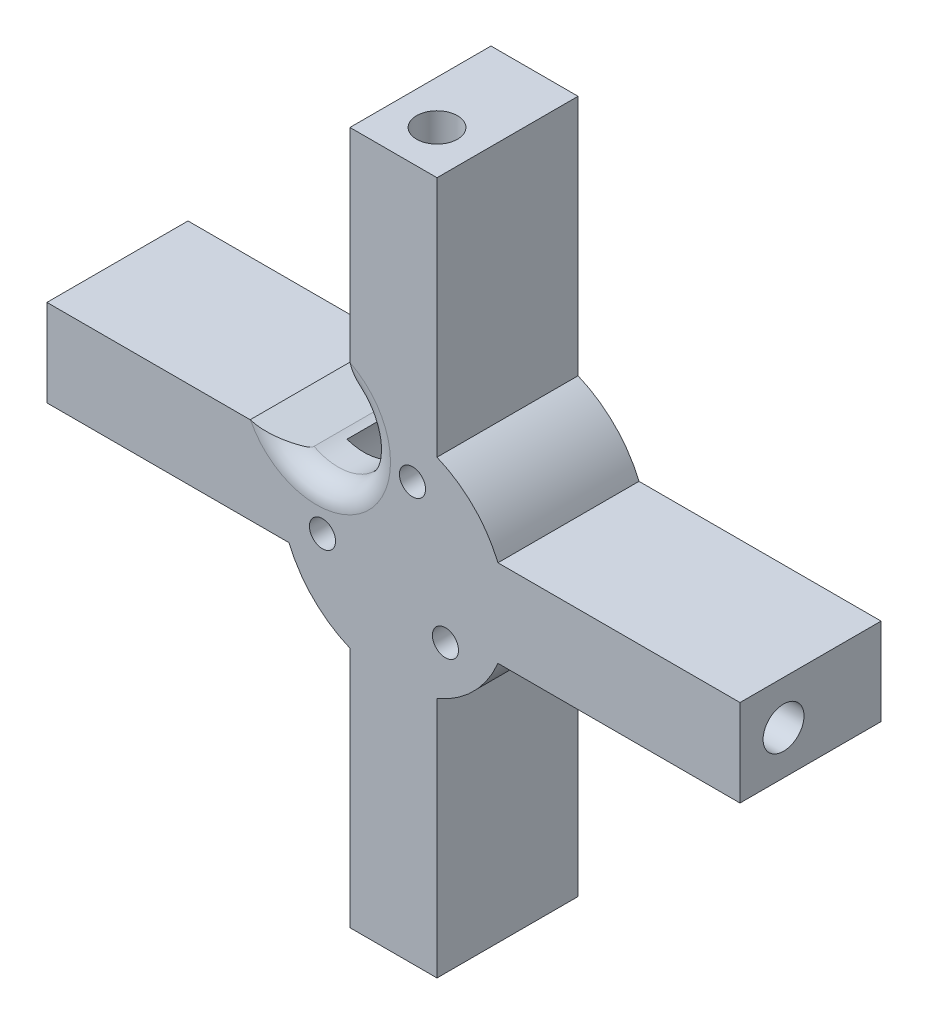
from build123d import *

# Parameters (mm, degrees)
BOSS_EXTRUDE1_DEPTH     = 22.7
SKETCH5_R               = 1.5
CUT_EXTRUDE1_DEPTH      = 70
CUT_EXTRUDE3_DEPTH      = 17.25
CUT_EXTRUDE3_DEPTH_BACK = 17.25
SKETCH6_R               = 11.25
SKETCH7_R               = 2
CUT_EXTRUDE4_DEPTH      = 3
CUT_EXTRUDE5_DEPTH      = 58
CUT_EXTRUDE5_DEPTH_BACK = 66
SKETCH8_W               = 6.5
SKETCH8_H               = 79.6
SKETCH9_R               = 2.35
SKETCH9_R_2             = 1.55
CUT_EXTRUDE7_DEPTH      = 4
SKETCH9_3_R             = 1.55
CUT_EXTRUDE20_DEPTH     = 12
SKETCH21_R              = 2.35
SKETCH21_R_2            = 1.55
CUT_EXTRUDE22_DEPTH     = 4
SKETCH21_2_R            = 1.55
CUT_EXTRUDE23_DEPTH     = 12
CUT_EXTRUDE24_START     = -4
SKETCH19_R              = 2.35
SKETCH19_R_2            = 1.55
CUT_EXTRUDE24_DEPTH     = 4
CUT_EXTRUDE25_START     = -12
SKETCH19_2_R            = 1.55
CUT_EXTRUDE25_DEPTH     = 12
CUT_EXTRUDE26_START     = -4
SKETCH20_R              = 2.35
SKETCH20_R_2            = 1.55
CUT_EXTRUDE26_DEPTH     = 4
CUT_EXTRUDE27_START     = -12
SKETCH20_2_R            = 1.55
CUT_EXTRUDE27_DEPTH     = 12
FILLET2_R               = 2.5
BOSS_EXTRUDE2_DEPTH     = 0.5


with BuildPart() as part:
    # Sketch4 → Boss-Extrude1 (new body)
    with BuildSketch(Plane.XY):
        with BuildLine():
            Line((-5, 39.8), (-5, 12))
            ThreePointArc((-5, 12), (-9.192388155, 9.192388155), (-12, 5))
            Line((-12, 5), (-39.8, 5))
            Line((-39.8, 5), (-39.8, -5))
            Line((-39.8, -5), (-12, -5))
            ThreePointArc((-12, -5), (-9.192388155, -9.192388155), (-5, -12))
            Line((-5, -12), (-5, -39.8))
            Line((-5, -39.8), (5, -39.8))
            Line((5, -39.8), (5, -12))
            ThreePointArc((5, -12), (9.192388155, -9.192388155), (12, -5))
            Line((12, -5), (39.8, -5))
            Line((39.8, -5), (39.8, 5))
            Line((39.8, 5), (12, 5))
            ThreePointArc((12, 5), (9.192388155, 9.192388155), (5, 12))
            Line((5, 12), (5, 39.8))
            Line((5, 39.8), (-5, 39.8))
        make_face()
    extrude(amount=-BOSS_EXTRUDE1_DEPTH)

    # Sketch5 → Cut-Extrude1 (cut)
    with BuildSketch(Plane.XY):
        with Locations((2.184887392, 8.154110756)):
            Circle(SKETCH5_R)
        with Locations((-8.154110756, -2.184887392)):
            Circle(SKETCH5_R)
        with Locations((5.969223364, -5.969223364)):
            Circle(SKETCH5_R)
        with BuildLine():
            Line((-5, 16.456455054), (-3.523070126, 11.621395871))
            ThreePointArc((-3.523070126, 11.621395871), (-4.596194078, 4.596194078), (-11.621395871, 3.523070126))
            Line((-11.621395871, 3.523070126), (-16.456455054, 5))
            Line((-16.456455054, 5), (-14.526937175, 6.929517879))
            ThreePointArc((-14.526937175, 6.929517879), (-13.081475452, 13.081475452), (-6.929517879, 14.526937175))
            Line((-6.929517879, 14.526937175), (-5, 16.456455054))
        make_face()
    extrude(amount=-CUT_EXTRUDE1_DEPTH, mode=Mode.SUBTRACT)

    # Sketch6 → Cut-Extrude3 (cut, two sides: drawn at the far end of the back side and taken through both)
    with BuildSketch(Plane(origin=(0, 0, -22.7), x_dir=(-1, 0, 0), z_dir=(0, 0, -1)).offset(-CUT_EXTRUDE3_DEPTH_BACK)):
        Circle(SKETCH6_R)
    extrude(amount=CUT_EXTRUDE3_DEPTH + CUT_EXTRUDE3_DEPTH_BACK, mode=Mode.SUBTRACT)

    # Sketch7 → Cut-Extrude4 (cut)
    with BuildSketch(Plane(origin=(0, 0, -5.45), x_dir=(-1, 0, 0), z_dir=(0, 0, -1))):
        with Locations((-2.184887392, 8.154110756)):
            Circle(SKETCH7_R)
        with Locations((-5.969223364, -5.969223364)):
            Circle(SKETCH7_R)
        with Locations((8.154110756, -2.184887392)):
            Circle(SKETCH7_R)
    extrude(amount=-CUT_EXTRUDE4_DEPTH, mode=Mode.SUBTRACT)

    # Sketch8 → Cut-Extrude5 (cut, two sides: drawn at the far end of the back side and taken through both)
    with BuildSketch(Plane.ZY.offset(5).offset(-CUT_EXTRUDE5_DEPTH_BACK)):
        with Locations((-19.45, 0)):
            Rectangle(SKETCH8_W, SKETCH8_H)
    extrude(amount=CUT_EXTRUDE5_DEPTH + CUT_EXTRUDE5_DEPTH_BACK, mode=Mode.SUBTRACT)

    # Sketch9 → Cut-Extrude7 (cut)
    with BuildSketch(Plane(origin=(0, 39.8, 0), x_dir=(1, 0, 0), z_dir=(0, 1, 0))):
        with Locations((0, 5)):
            Circle(SKETCH9_R)
        with Locations((0, 5)):
            Circle(SKETCH9_R_2, mode=Mode.SUBTRACT)
    extrude(amount=-CUT_EXTRUDE7_DEPTH, mode=Mode.SUBTRACT)

    # Sketch9_3 → Cut-Extrude20 (cut)
    with BuildSketch(Plane(origin=(0, 39.8, 0), x_dir=(1, 0, 0), z_dir=(0, 1, 0))):
        with Locations((0, 5)):
            Circle(SKETCH9_3_R)
    extrude(amount=-CUT_EXTRUDE20_DEPTH, mode=Mode.SUBTRACT)

    # Sketch21 → Cut-Extrude22 (cut)
    with BuildSketch(Plane.ZY.offset(39.8)):
        with Locations((-5, 0)):
            Circle(SKETCH21_R)
        with Locations((-5, 0)):
            Circle(SKETCH21_R_2, mode=Mode.SUBTRACT)
    extrude(amount=-CUT_EXTRUDE22_DEPTH, mode=Mode.SUBTRACT)

    # Sketch21_2 → Cut-Extrude23 (cut)
    with BuildSketch(Plane.ZY.offset(39.8)):
        with Locations((-5, 0)):
            Circle(SKETCH21_2_R)
    extrude(amount=-CUT_EXTRUDE23_DEPTH, mode=Mode.SUBTRACT)

    # Sketch19 → Cut-Extrude24 (cut)
    with BuildSketch(Plane(origin=(39.8, 0, 0), x_dir=(0, 0, -1), z_dir=(1, 0, 0)).offset(CUT_EXTRUDE24_START)):
        with Locations((5, 0)):
            Circle(SKETCH19_R)
        with Locations((5, 0)):
            Circle(SKETCH19_R_2, mode=Mode.SUBTRACT)
    extrude(amount=CUT_EXTRUDE24_DEPTH, mode=Mode.SUBTRACT)

    # Sketch19_2 → Cut-Extrude25 (cut)
    with BuildSketch(Plane(origin=(39.8, 0, 0), x_dir=(0, 0, -1), z_dir=(1, 0, 0)).offset(CUT_EXTRUDE25_START)):
        with Locations((5, 0)):
            Circle(SKETCH19_2_R)
    extrude(amount=CUT_EXTRUDE25_DEPTH, mode=Mode.SUBTRACT)

    # Sketch20 → Cut-Extrude26 (cut)
    with BuildSketch(Plane.XZ.offset(39.8).offset(CUT_EXTRUDE26_START)):
        with Locations((0, -5)):
            Circle(SKETCH20_R)
        with Locations((0, -5)):
            Circle(SKETCH20_R_2, mode=Mode.SUBTRACT)
    extrude(amount=CUT_EXTRUDE26_DEPTH, mode=Mode.SUBTRACT)

    # Sketch20_2 → Cut-Extrude27 (cut)
    with BuildSketch(Plane.XZ.offset(39.8).offset(CUT_EXTRUDE27_START)):
        with Locations((0, -5)):
            Circle(SKETCH20_2_R)
    extrude(amount=CUT_EXTRUDE27_DEPTH, mode=Mode.SUBTRACT)

    # Fillet2
    fillet2_edges = [part.edges().sort_by_distance(p)[0] for p in [
        (-4.596194078, 4.596194078, 0),
    ]]
    fillet(fillet2_edges, radius=FILLET2_R)

    # Sketch22 → Boss-Extrude2 (add)
    with BuildSketch(Plane(origin=(0, 0, -5.45), x_dir=(-1, 0, 0), z_dir=(0, 0, -1))):
        Polygon((-1.363621795, 3.175), (-1.058333333, 3.175), (0, 0.672906651), (1.058333333, 3.175), (1.363621795, 3.175), (0.020352564, 0), (-0.020352564, 0), align=None)
    extrude(amount=BOSS_EXTRUDE2_DEPTH)


solid = part.part
